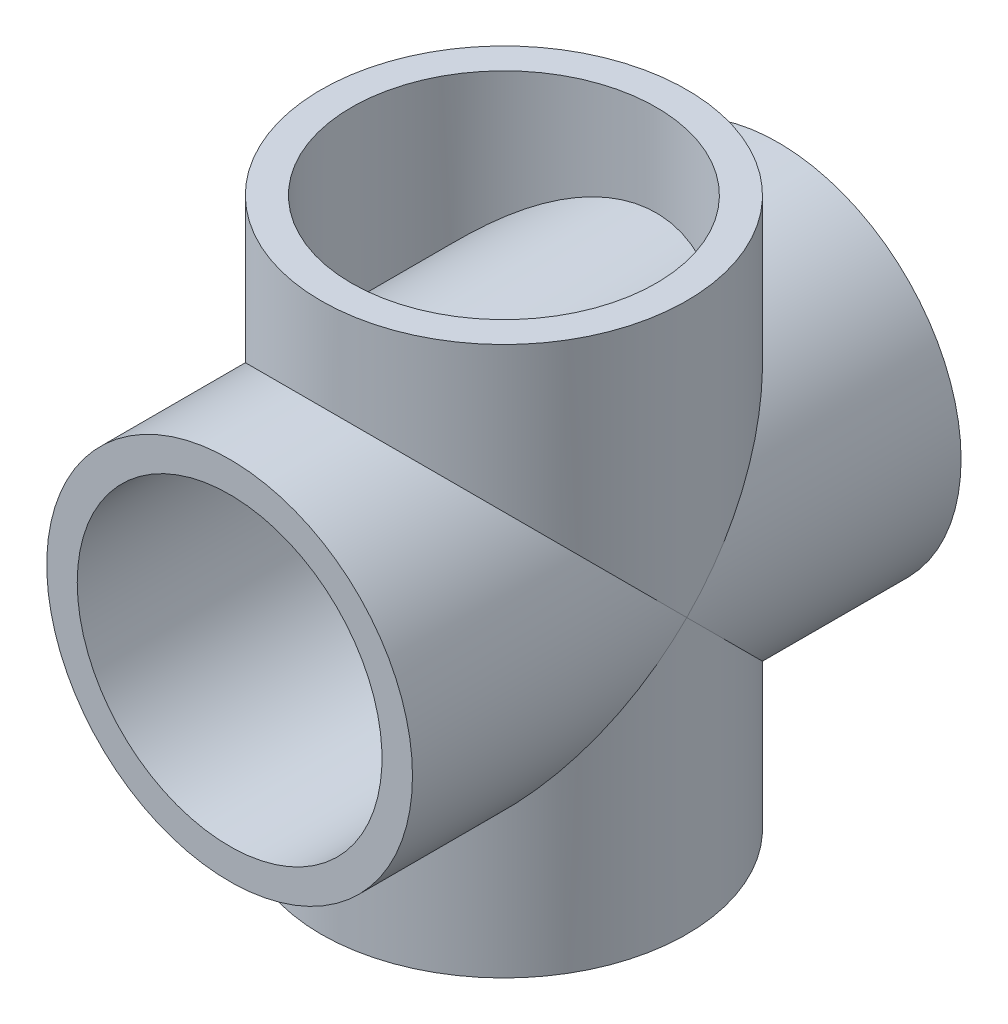
from build123d import *

# Parameters (mm, degrees)
BOSS_EXTRUDE1_DEPTH      = 9
BOSS_EXTRUDE1_DEPTH_BACK = 9
SKETCH1_R                = 6
SKETCH1_R_2              = 5
BOSS_EXTRUDE2_DEPTH      = 9
BOSS_EXTRUDE2_DEPTH_BACK = 9
SKETCH2_R                = 6
SKETCH3_R                = 5
CUT_EXTRUDE1_DEPTH       = 22.000000043


with BuildPart() as part:
    # Sketch1 → Boss-Extrude1 (new, two sides: drawn at the far end of the back side and taken through both)
    with BuildSketch(Plane(origin=(0, 0, 0), x_dir=(1, 0, 0), z_dir=(0, 1, 0)).offset(-BOSS_EXTRUDE1_DEPTH_BACK)):
        Circle(SKETCH1_R)
        Circle(SKETCH1_R_2, mode=Mode.SUBTRACT)
    extrude(amount=BOSS_EXTRUDE1_DEPTH + BOSS_EXTRUDE1_DEPTH_BACK)

    # Sketch2 → Boss-Extrude2 (add, two sides: drawn at the far end of the back side and taken through both)
    with BuildSketch(Plane.XY.offset(-BOSS_EXTRUDE2_DEPTH_BACK)):
        Circle(SKETCH2_R)
    extrude(amount=BOSS_EXTRUDE2_DEPTH + BOSS_EXTRUDE2_DEPTH_BACK)

    # Sketch3 → Cut-Extrude1 (cut, through all)
    with BuildSketch(Plane(origin=(0, 0, -9), x_dir=(-1, 0, 0), z_dir=(0, 0, -1))):
        Circle(SKETCH3_R)
    extrude(amount=-CUT_EXTRUDE1_DEPTH, mode=Mode.SUBTRACT)


solid = part.part
